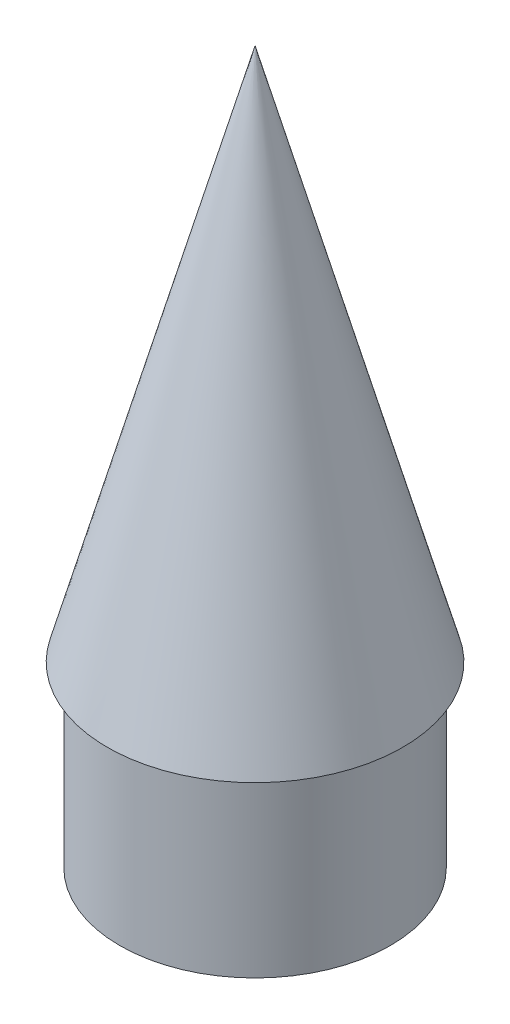
from build123d import *

# Parameters (mm, degrees)
SKETCH4_W          = 50.332275622
SKETCH4_H          = 47.611612075
CUT_EXTRUDE1_DEPTH = 10


with BuildPart() as part:
    # Sketch1 → Revolve3 (revolve)
    with BuildSketch(Plane.XY, mode=Mode.PRIVATE) as revolve3_sk:
        Polygon((0, 150), (-41.5, 0), (-33, 0), (-33, 2), (-38.871533471, 2), (0, 142.499518572), align=None)
    revolve(revolve3_sk.sketch.rotate(Axis((0, 2, 0), (0, 1, 0)), 270), axis=Axis((0, 2, 0), (0, 1, 0)))

    # Sketch2 → Revolve6 (revolve)
    with BuildSketch(Plane.XY, mode=Mode.PRIVATE) as revolve6_sk:
        Polygon((33, 30.722891566), (33, -50), (38, -50), (38, 0), (41.5, 0), align=None)
    revolve(revolve6_sk.sketch.rotate(Axis((0, 0, 0), (0, -1, 0)), 270), axis=Axis((0, 0, 0), (0, -1, 0)))

    # Sketch4 → Cut-Extrude1 (cut)
    with BuildSketch(Plane(origin=(0, 149.9, 0), x_dir=(1, 0, 0), z_dir=(0, 1, 0))):
        with Locations((0.291499666, 1.846164549)):
            Rectangle(SKETCH4_W, SKETCH4_H)
    extrude(amount=CUT_EXTRUDE1_DEPTH, mode=Mode.SUBTRACT)


solid = part.part
